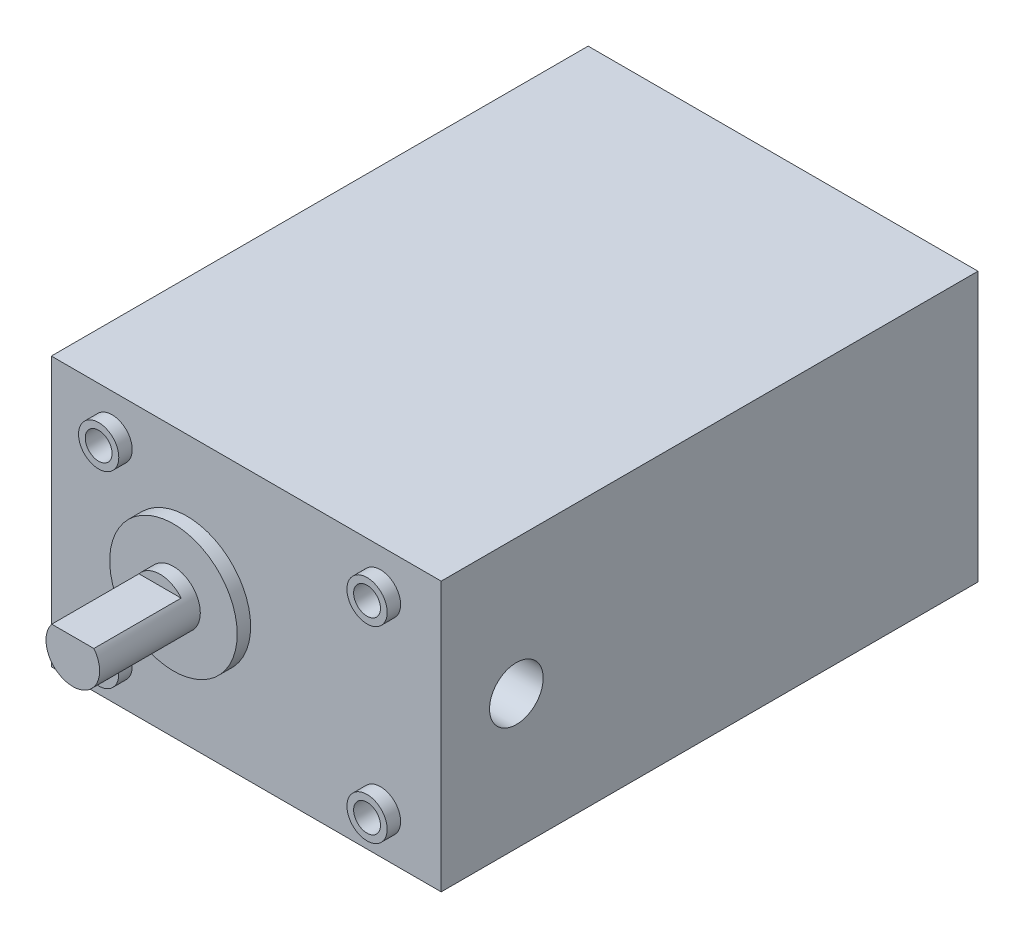
from build123d import *

# Parameters (mm, degrees)
SKETCH1_W           = 58.1
SKETCH1_H           = 40.11
BOSS_EXTRUDE1_DEPTH = 80
SKETCH2_R           = 9.5
BOSS_EXTRUDE2_DEPTH = 2
SKETCH3_R           = 4
BOSS_EXTRUDE3_DEPTH = 15
SKETCH4_W           = 6.276876118
SKETCH4_H           = 1.998885949
CUT_EXTRUDE1_DEPTH  = 13
SKETCH5_R           = 3
BOSS_EXTRUDE4_DEPTH = 2
SKETCH6_R           = 2
CUT_EXTRUDE2_DEPTH  = 8
SKETCH7_R           = 4
CUT_EXTRUDE3_DEPTH  = 25.4


with BuildPart() as part:
    # Sketch1 → Boss-Extrude1 (new body)
    with BuildSketch(Plane.XY):
        with Locations((29.05, 20.055)):
            Rectangle(SKETCH1_W, SKETCH1_H)
    extrude(amount=BOSS_EXTRUDE1_DEPTH)

    # Sketch2 → Boss-Extrude2 (add)
    with BuildSketch(Plane.XY.offset(80)):
        with Locations((20.2, 20.055)):
            Circle(SKETCH2_R)
    extrude(amount=BOSS_EXTRUDE2_DEPTH)

    # Sketch3 → Boss-Extrude3 (add)
    with BuildSketch(Plane.XY.offset(82)):
        with Locations((20.2, 20.055)):
            Circle(SKETCH3_R)
    extrude(amount=BOSS_EXTRUDE3_DEPTH)

    # Sketch4 → Cut-Extrude1 (cut)
    with BuildSketch(Plane.XY.offset(97)):
        with Locations((20.2, 23.534403972)):
            Rectangle(SKETCH4_W, SKETCH4_H)
    extrude(amount=-CUT_EXTRUDE1_DEPTH, mode=Mode.SUBTRACT)

    # Sketch5 → Boss-Extrude4 (add)
    with BuildSketch(Plane.XY.offset(80)):
        with Locations((9.05, 34.055)):
            Circle(SKETCH5_R)
        with Locations((49.05, 34.055)):
            Circle(SKETCH5_R)
        with Locations((49.05, 6.055)):
            Circle(SKETCH5_R)
        with Locations((9.05, 6.055)):
            Circle(SKETCH5_R)
    extrude(amount=BOSS_EXTRUDE4_DEPTH)

    # Sketch6 → Cut-Extrude2 (cut)
    with BuildSketch(Plane.XY.offset(82)):
        with Locations((9.05, 34.055)):
            Circle(SKETCH6_R)
        with Locations((49.05, 34.055)):
            Circle(SKETCH6_R)
        with Locations((49.05, 6.055)):
            Circle(SKETCH6_R)
        with Locations((9.05, 6.055)):
            Circle(SKETCH6_R)
    extrude(amount=-CUT_EXTRUDE2_DEPTH, mode=Mode.SUBTRACT)

    # Sketch7 → Cut-Extrude3 (cut)
    with BuildSketch(Plane(origin=(58.1, 0, 0), x_dir=(0, 0, -1), z_dir=(1, 0, 0))):
        with Locations((-68.797911108, 20)):
            Circle(SKETCH7_R)
    extrude(amount=-CUT_EXTRUDE3_DEPTH, mode=Mode.SUBTRACT)


solid = part.part
